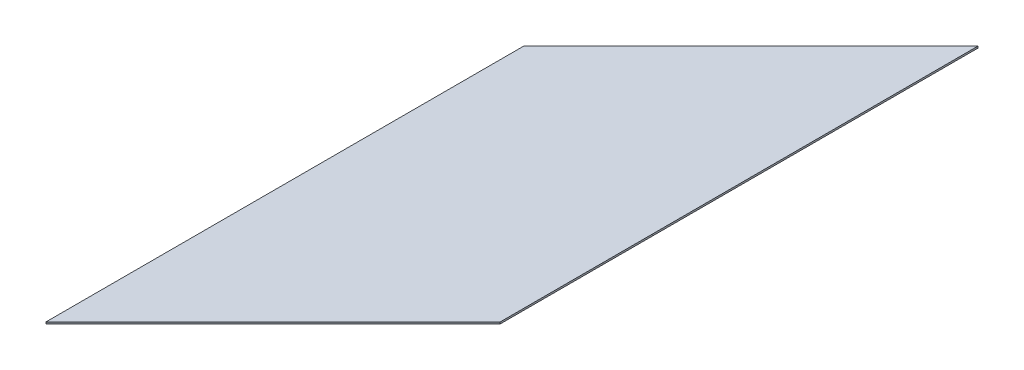
from build123d import *

# Parameters (mm, degrees)
BOSS_EXTRUDE1_DEPTH = 2.54


with BuildPart() as part:
    # Sketch1 → Boss-Extrude1 (new body)
    with BuildSketch(Plane(origin=(0, 0, 0), x_dir=(1, 0, 0), z_dir=(0, 1, 0))):
        Polygon((322.200496223, 538.057476738), (322.200496223, 1000), (0, 677.799503777), (0, 0), (322.2, 322.2), (322.2, 468.24956238), align=None)
    extrude(amount=BOSS_EXTRUDE1_DEPTH)


solid = part.part
